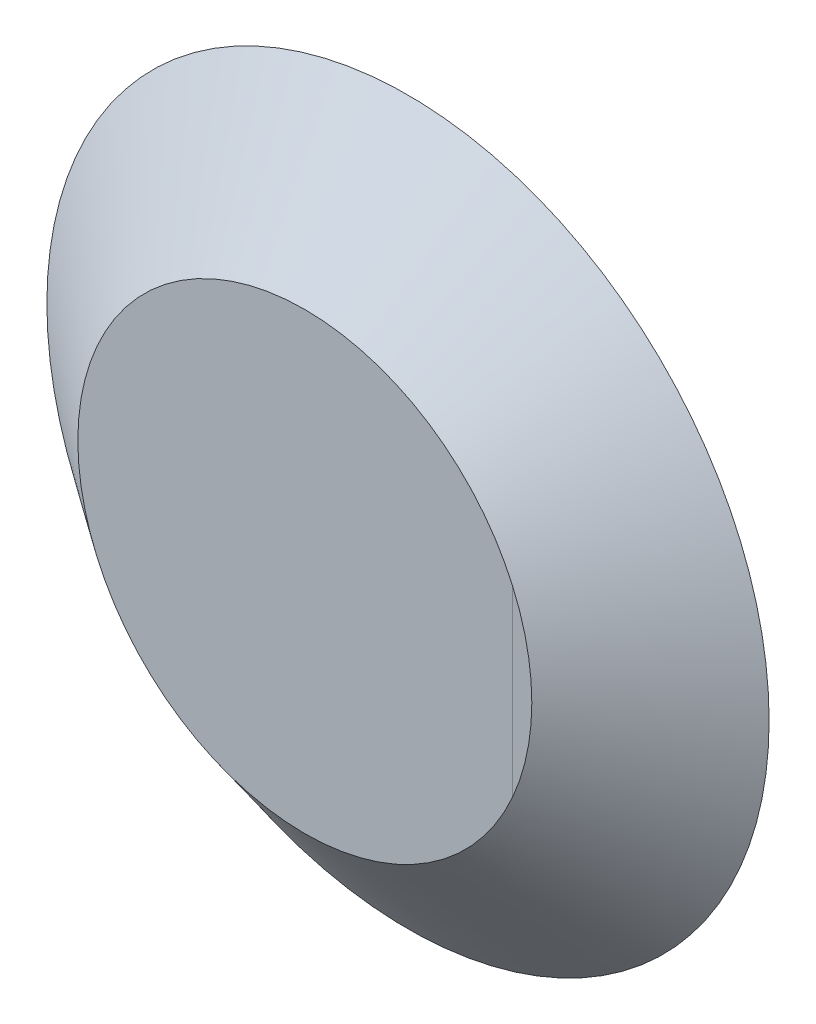
from build123d import *

# Parameters (mm, degrees)
SKETCH_1_R      = 44
EXTRUDE_1_DEPTH = 20
SKETCH_4_R      = 70


with BuildPart() as part:
    # 草图1 → 凸台-拉伸1 (new body)
    with BuildSketch(Plane.XY):
        Circle(SKETCH_1_R)
    extrude(amount=EXTRUDE_1_DEPTH)

    # 草图4 → section 1 of loft_3
    with BuildSketch(Plane(origin=(0, 0, 0), x_dir=(-1, 0, 0), z_dir=(0, 0, -1)), mode=Mode.PRIVATE) as loft_3_s1:
        Circle(SKETCH_4_R)
    # loft up to a face of the part (loft_3)
    loft([Face(Wire([part.edges().sort_by_distance((-30.120072661, 32.074619607, 20))[0]])), loft_3_s1.sketch])


solid = part.part
